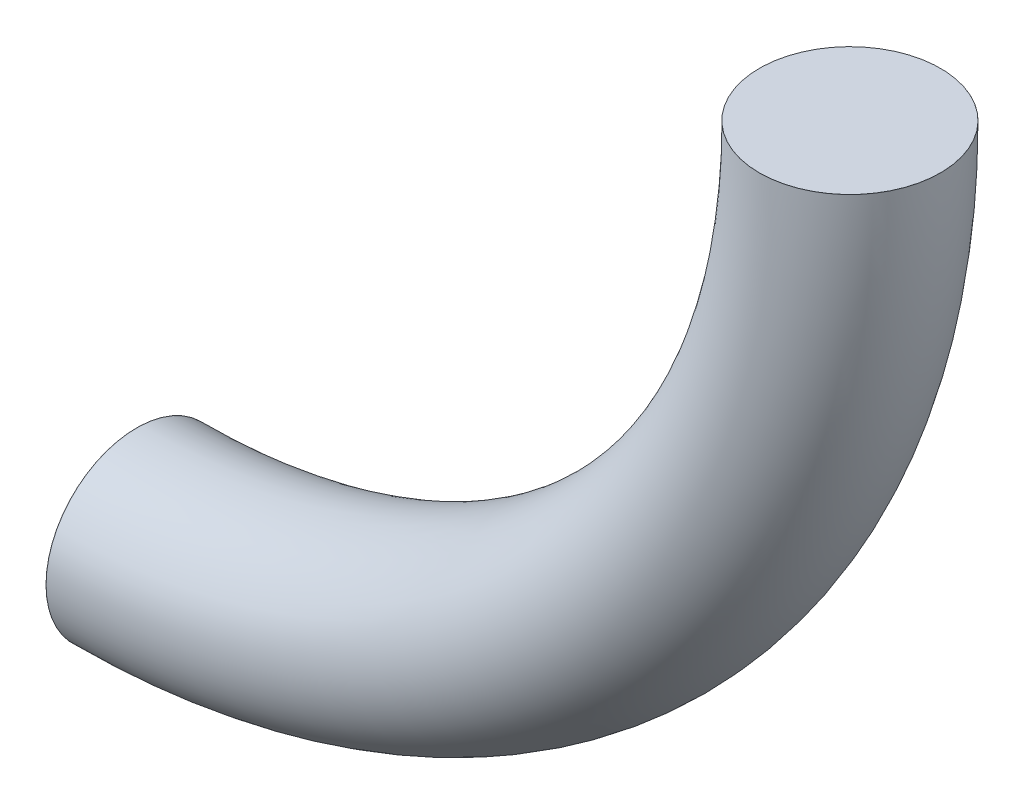
from build123d import *

# Parameters (mm, degrees)
CROQUIS3_R = 6.35


with BuildPart() as part:
    # Barrer1: sweep along a path in Croquis4
    with BuildLine(Plane.XY) as barrer1_path:
        Line((0, 0), (0, -0.01))
        ThreePointArc((0, -0.01), (-14.644660941, -35.365339059), (-50, -50.01))
        Line((-50, -50.01), (-50.01, -50.01))
    # Croquis3 → Barrer1 (sweep)
    with BuildSketch(Plane(origin=(0, 0, 0), x_dir=(1, 0, 0), z_dir=(0, 1, 0))):
        Circle(CROQUIS3_R)
    sweep(path=barrer1_path.line)


solid = part.part
